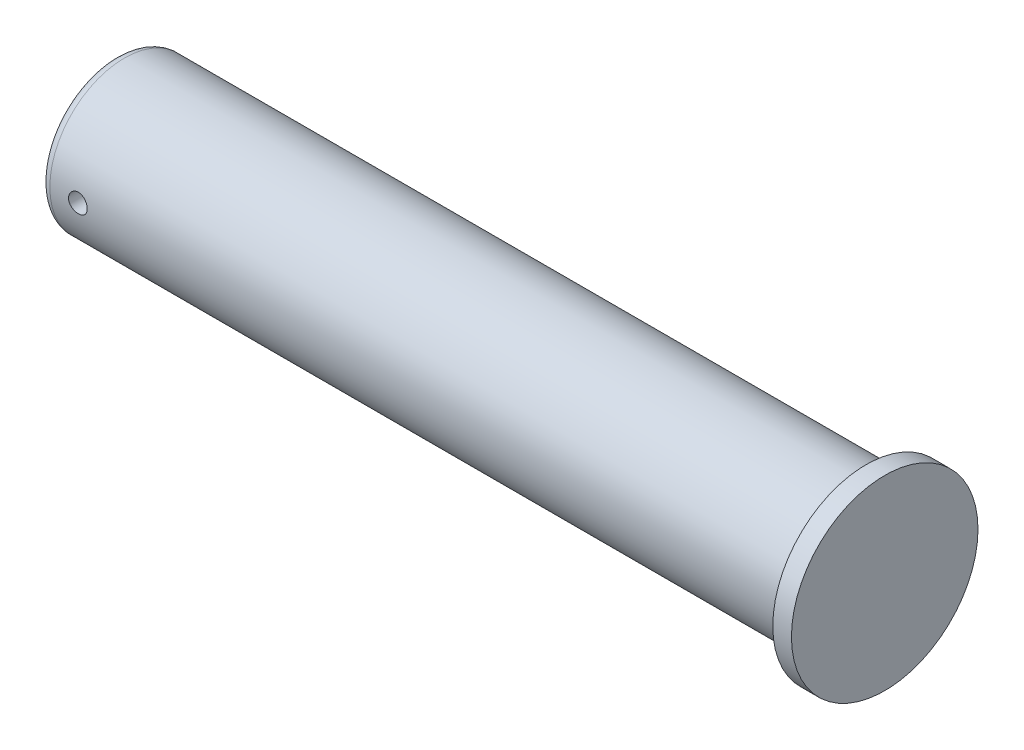
from build123d import *

# Parameters (mm, degrees)
SCHNITT_LINEAR_AUSTRAGEN1_REACH             = 12
SKIZZE2_R                                   = 1
SCHNITT_LINEAR_AUSTRAGEN1_DIRECTION_2_DEPTH = 11
VERRUNDUNG1_R                               = 1


with BuildPart() as part:
    # Skizze1 → Rotation1 (revolve)
    with BuildSketch(Plane.XY):
        Polygon((0, 0), (0, 8), (80.5, 8), (80.5, 10), (82.5, 10), (82.5, 0), align=None)
    revolve(axis=Axis((-15.956588212, 0, 0), (1, 0, 0)))

    # Skizze2 → Schnitt-Linear austragen1 (cut, up to next)
    with BuildSketch(Plane.XY, mode=Mode.PRIVATE) as schnitt_linear_austragen1_sk1:
        with Locations((4, 0)):
            Circle(SKIZZE2_R)
    schnitt_linear_austragen1_tool1 = extrude(schnitt_linear_austragen1_sk1.sketch, amount=-SCHNITT_LINEAR_AUSTRAGEN1_REACH, mode=Mode.PRIVATE) & part.part
    add(schnitt_linear_austragen1_tool1.solids().sort_by_distance((4, 0, 0))[0], mode=Mode.SUBTRACT)

    # Skizze2 → Schnitt-Linear austragen1 direction 2 (cut)
    with BuildSketch(Plane.XY):
        with Locations((4, 0)):
            Circle(SKIZZE2_R)
    extrude(amount=SCHNITT_LINEAR_AUSTRAGEN1_DIRECTION_2_DEPTH, mode=Mode.SUBTRACT)

    # Verrundung1
    verrundung1_edges = [part.edges().sort_by_distance(p)[0] for p in [
        (0, -8, 0),
    ]]
    fillet(verrundung1_edges, radius=VERRUNDUNG1_R)


solid = part.part
